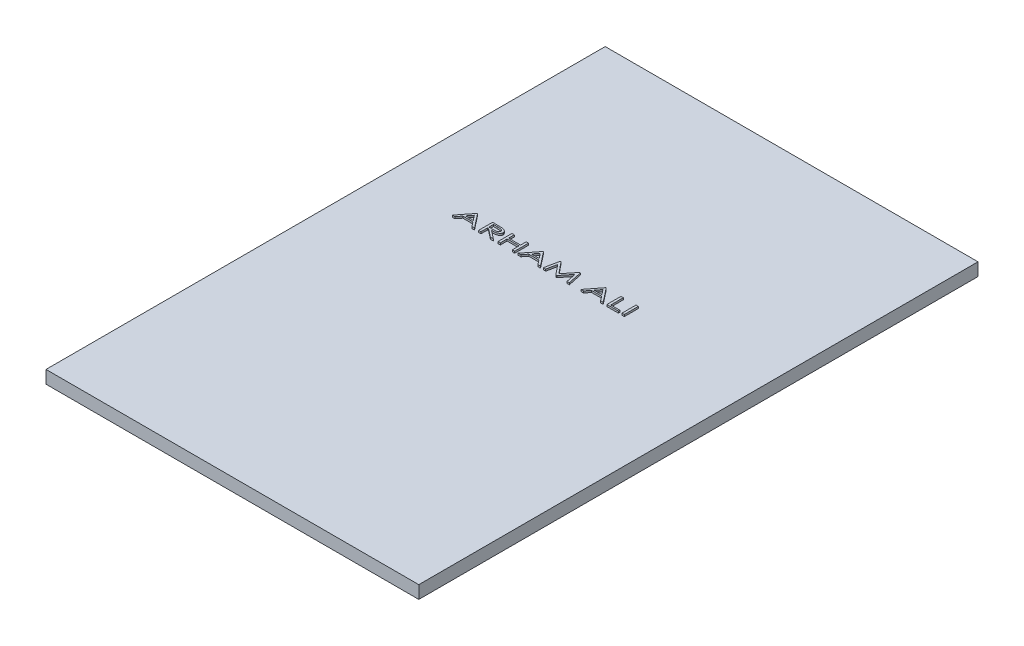
from build123d import *

# Parameters (mm, degrees)
SKETCH2_W           = 508
SKETCH2_H           = 762
BOSS_EXTRUDE1_DEPTH = 20
SKETCH6_OUTSIDE_W   = 693.206
SKETCH6_OUTSIDE_H   = 947.206
SKETCH6_OUTSIDE_W_2 = 3.175
SKETCH6_OUTSIDE_H_2 = 19.05
CUT_EXTRUDE3_DEPTH  = 2.54


with BuildPart() as part:
    # Sketch2 → Boss-Extrude1 (new body)
    with BuildSketch(Plane(origin=(0, 0, 0), x_dir=(1, 0, 0), z_dir=(0, 1, 0))):
        with Locations((254, 381)):
            Rectangle(SKETCH2_W, SKETCH2_H)
    extrude(amount=BOSS_EXTRUDE1_DEPTH)

    # Sketch6 outside → Cut-Extrude3 (cut)
    with BuildSketch(Plane(origin=(0, 20, 0), x_dir=(1, 0, 0), z_dir=(0, 1, 0))):
        with Locations((254, 381)):
            Rectangle(SKETCH6_OUTSIDE_W, SKETCH6_OUTSIDE_H)
        Polygon((112.668355558, 475.393217302), (127.566432481, 456.343217302), (124.063247385, 456.343217302), (119.285482962, 462.448986533), (105.562766616, 462.448986533), (100.785002193, 456.343217302), (97.281817096, 456.343217302), (112.179894019, 475.393217302), align=None, mode=Mode.SUBTRACT)
        with BuildLine():
            Line((133.183740173, 475.393217302), (139.407808683, 475.393217302))
            add(Edge.make_bspline(
                [(139.407808683, 475.393217302), (139.823763227, 475.392378699), (140.621344739, 475.390770701), (141.765017154, 475.381609756), (142.802912592, 475.35580072), (143.735599265, 475.333324697), (144.563550459, 475.292376921), (145.287803213, 475.254071392), (145.907678728, 475.2021541), (146.284547806, 475.155133192), (146.456156039, 475.133722109)],
                knots=[0, 0, 0, 0, 0.001247872, 0.002392761, 0.003430995, 0.004362508, 0.005191481, 0.005917756, 0.006538269, 0.007057049, 0.007057049, 0.007057049, 0.007057049], degree=3))
            add(Edge.make_bspline(
                [(146.456156039, 475.133722109), (146.683056001, 475.099492871), (147.127616215, 475.032428262), (147.774064025, 474.888586417), (148.389431124, 474.72132443), (148.974312987, 474.528541177), (149.524563918, 474.302786296), (150.041723997, 474.049764286), (150.528677863, 473.772907189), (150.975574153, 473.46359409), (151.386615983, 473.139062254), (151.741955027, 472.787990224), (152.04298262, 472.41754671), (152.294271383, 472.031924823), (152.486834714, 471.624818037), (152.619908964, 471.198147312), (152.70841167, 470.755211902), (152.717577639, 470.451788145), (152.722201712, 470.2987161)],
                knots=[0, 0, 0, 0, 0.000688223, 0.00134842, 0.001985344, 0.002600791, 0.003194646, 0.003768091, 0.004327096, 0.004873279, 0.005397143, 0.005896353, 0.006368379, 0.006826725, 0.007273975, 0.007714484, 0.008165043, 0.008623754, 0.008623754, 0.008623754, 0.008623754], degree=3))
            add(Edge.make_bspline(
                [(152.722201712, 470.2987161), (152.718724097, 470.169997066), (152.711837042, 469.915082337), (152.651070111, 469.539710452), (152.561871631, 469.175581086), (152.428807906, 468.824679768), (152.262177532, 468.484684189), (152.052060695, 468.158011283), (151.808796064, 467.84213124), (151.528662222, 467.539911251), (151.214165477, 467.253447515), (150.86673255, 466.98167897), (150.484645364, 466.732261425), (150.074106621, 466.496788734), (149.629019948, 466.284553496), (149.153033662, 466.086062558), (148.6444167, 465.907510462), (148.102281013, 465.745484665), (147.517192179, 465.605376983), (146.883884797, 465.477667431), (146.195431943, 465.378563913), (145.455095555, 465.289576637), (144.662098406, 465.222350172), (143.815913209, 465.173142048), (142.917576782, 465.142533143), (142.300441343, 465.137902034), (141.983680077, 465.135524994)],
                knots=[0, 0, 0, 0, 0.000385899, 0.000764232, 0.001138152, 0.001508865, 0.001887737, 0.002272029, 0.002671992, 0.003082468, 0.003506536, 0.003946995, 0.004404228, 0.004874244, 0.005365797, 0.005882439, 0.00642074, 0.006982174, 0.00757916, 0.00822503, 0.008919613, 0.009665122, 0.010461839, 0.011306656, 0.012207775, 0.013158054, 0.013158054, 0.013158054, 0.013158054], degree=3))
            Line((141.983680077, 465.135524994), (153.21066325, 456.343217302))
            Line((153.21066325, 456.343217302), (149.219016616, 456.343217302))
            Line((149.219016616, 456.343217302), (137.992033443, 465.135524994))
            Line((137.992033443, 465.135524994), (136.358740173, 465.135524994))
            Line((136.358740173, 465.135524994), (136.358740173, 456.343217302))
            Line((136.358740173, 456.343217302), (133.183740173, 456.343217302))
            Line((133.183740173, 456.343217302), (133.183740173, 475.393217302))
        make_face(mode=Mode.SUBTRACT)
        Polygon((159.56066325, 475.393217302), (162.73566325, 475.393217302), (162.73566325, 467.577832686), (179.099124789, 467.577832686), (179.099124789, 475.393217302), (182.274124789, 475.393217302), (182.274124789, 456.343217302), (179.099124789, 456.343217302), (179.099124789, 465.623986533), (162.73566325, 465.623986533), (162.73566325, 456.343217302), (159.56066325, 456.343217302), align=None, mode=Mode.SUBTRACT)
        Polygon((202.545278635, 475.393217302), (217.443355558, 456.343217302), (213.940170462, 456.343217302), (209.162406039, 462.448986533), (195.439689693, 462.448986533), (190.661925269, 456.343217302), (187.158740173, 456.343217302), (202.056817096, 475.393217302), align=None, mode=Mode.SUBTRACT)
        Polygon((221.351047866, 456.343217302), (225.21676301, 475.393217302), (226.430284644, 475.393217302), (239.057778635, 459.762448071), (251.582237769, 475.393217302), (252.784311087, 475.393217302), (256.764509404, 456.343217302), (253.639118779, 456.343217302), (250.780855558, 470.020140379), (239.820999789, 456.343217302), (238.382327914, 456.343217302), (227.334701712, 470.020140379), (224.560392818, 456.343217302), align=None, mode=Mode.SUBTRACT)
        Polygon((288.026047866, 475.393217302), (302.924124789, 456.343217302), (299.420939693, 456.343217302), (294.643175269, 462.448986533), (280.920458923, 462.448986533), (276.1426945, 456.343217302), (272.639509404, 456.343217302), (287.537586327, 475.393217302), align=None, mode=Mode.SUBTRACT)
        Polygon((308.052970943, 475.393217302), (311.227970943, 475.393217302), (311.227970943, 458.297063456), (323.683740173, 458.297063456), (323.683740173, 456.343217302), (308.052970943, 456.343217302), align=None, mode=Mode.SUBTRACT)
        with Locations((330.155855558, 465.868217302)):
            Rectangle(SKETCH6_OUTSIDE_W_2, SKETCH6_OUTSIDE_H_2, mode=Mode.SUBTRACT)
        Polygon((112.424124789, 471.226029802), (107.089208923, 464.402832686), (117.759040654, 464.402832686), align=None)
        with BuildLine():
            Line((136.358740173, 473.439371148), (136.358740173, 467.089371148))
            Line((136.358740173, 467.089371148), (141.739449308, 467.062658408))
            add(Edge.make_bspline(
                [(141.739449308, 467.062658408), (141.991332161, 467.062570255), (142.47864304, 467.06239971), (143.184616171, 467.084289384), (143.839948164, 467.10867955), (144.444364269, 467.146777703), (144.997978448, 467.195681875), (145.500873079, 467.255645837), (145.952984108, 467.327434732), (146.47691232, 467.436204996), (147.061780956, 467.606162217), (147.695856685, 467.857553859), (148.24254268, 468.173901575), (148.708862605, 468.532941393), (149.076294313, 468.937801288), (149.350210083, 469.367573464), (149.515171018, 469.827997025), (149.536557082, 470.144831857), (149.547201712, 470.302532206)],
                knots=[0, 0, 0, 0, 0.000755599, 0.001461836, 0.002118749, 0.002722901, 0.003278455, 0.003785868, 0.004241969, 0.004651361, 0.005390465, 0.006066519, 0.006692267, 0.007279327, 0.007825071, 0.008323828, 0.008800536, 0.009272948, 0.009272948, 0.009272948, 0.009272948], degree=3))
            add(Edge.make_bspline(
                [(149.547201712, 470.302532206), (149.536993762, 470.456644755), (149.516441351, 470.766930827), (149.343538354, 471.214450451), (149.074272534, 471.639913077), (148.694107695, 472.025978854), (148.240027969, 472.384546825), (147.70643729, 472.684529116), (147.110135759, 472.933964407), (146.560603748, 473.090886762), (146.068455921, 473.189669399), (145.637010141, 473.258184721), (145.148066892, 473.314398312), (144.601921018, 473.358279722), (144.000242016, 473.397166339), (143.341135293, 473.422930696), (142.624861794, 473.438251438), (142.127428511, 473.438988512), (141.869196904, 473.439371148)],
                knots=[0, 0, 0, 0, 0.000461039, 0.000928243, 0.001420535, 0.00196308, 0.002544783, 0.003151592, 0.003792993, 0.004480199, 0.004861886, 0.005298543, 0.005790347, 0.006337968, 0.006942119, 0.007599033, 0.008316623, 0.009091302, 0.009091302, 0.009091302, 0.009091302], degree=3))
            Line((141.869196904, 473.439371148), (136.358740173, 473.439371148))
        make_face()
        Polygon((202.301047866, 471.226029802), (196.966132, 464.402832686), (207.635963731, 464.402832686), align=None)
        Polygon((287.781817096, 471.226029802), (282.446901231, 464.402832686), (293.116732962, 464.402832686), align=None)
    extrude(amount=-CUT_EXTRUDE3_DEPTH, mode=Mode.SUBTRACT)


solid = part.part
